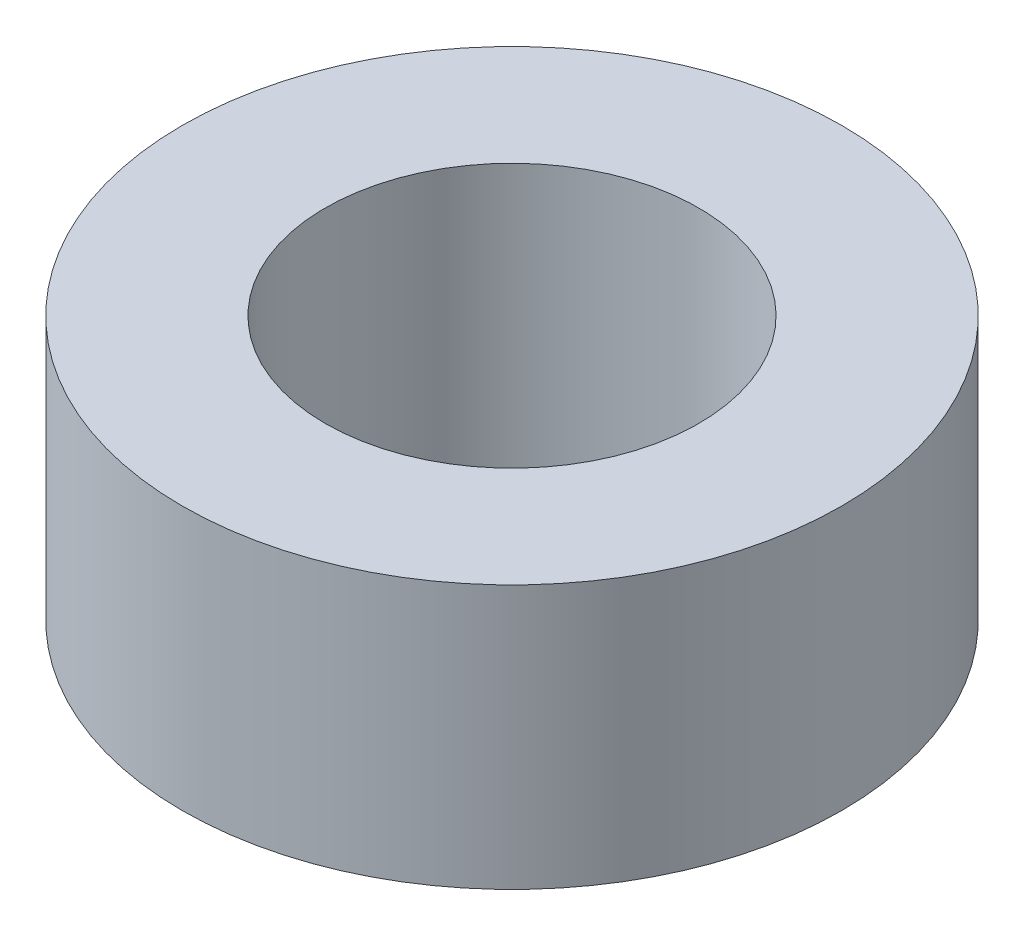
from build123d import *

# Parameters (mm, degrees)
SKETCH1_R           = 3.96875
SKETCH1_R_2         = 2.2479
BOSS_EXTRUDE1_DEPTH = 3.175


with BuildPart() as part:
    # Sketch1 → Boss-Extrude1 (new body)
    with BuildSketch(Plane(origin=(0, 0, 0), x_dir=(1, 0, 0), z_dir=(0, 1, 0))):
        Circle(SKETCH1_R)
        Circle(SKETCH1_R_2, mode=Mode.SUBTRACT)
    extrude(amount=BOSS_EXTRUDE1_DEPTH)


solid = part.part
